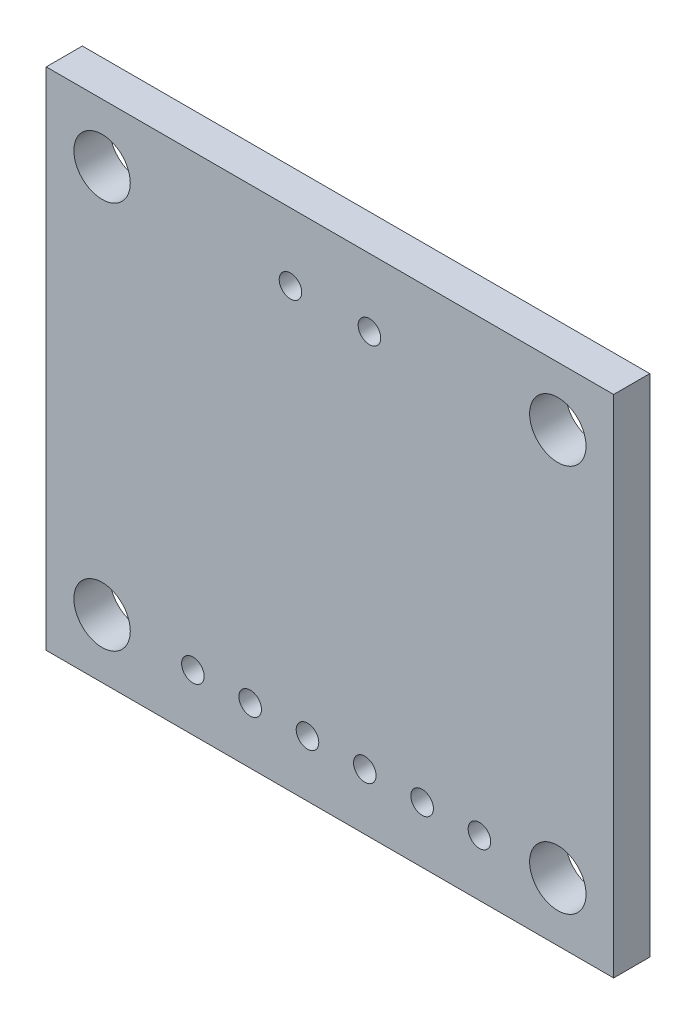
from build123d import *

# Parameters (mm, degrees)
SKETCH1_W           = 25.15
SKETCH1_H           = 22.4
SKETCH1_R           = 1.25
SKETCH1_R_2         = 0.5
BOSS_EXTRUDE1_DEPTH = 1.6


with BuildPart() as part:
    # Sketch1 → Boss-Extrude1 (new body)
    with BuildSketch(Plane.XY):
        Rectangle(SKETCH1_W, SKETCH1_H)
        with Locations((-10.1, 8.6)):
            Circle(SKETCH1_R, mode=Mode.SUBTRACT)
        with Locations((10.1, 8.6)):
            Circle(SKETCH1_R, mode=Mode.SUBTRACT)
        with Locations((-10.1, -8.6)):
            Circle(SKETCH1_R, mode=Mode.SUBTRACT)
        with Locations((10.1, -8.6)):
            Circle(SKETCH1_R, mode=Mode.SUBTRACT)
        with Locations((-1.75, 8.2)):
            Circle(SKETCH1_R_2, mode=Mode.SUBTRACT)
        with Locations((1.75, 8.2)):
            Circle(SKETCH1_R_2, mode=Mode.SUBTRACT)
        with Locations((-6.075, -8.7)):
            Circle(SKETCH1_R_2, mode=Mode.SUBTRACT)
        with Locations((-3.535, -8.7)):
            Circle(SKETCH1_R_2, mode=Mode.SUBTRACT)
        with Locations((-0.995, -8.7)):
            Circle(SKETCH1_R_2, mode=Mode.SUBTRACT)
        with Locations((1.545, -8.7)):
            Circle(SKETCH1_R_2, mode=Mode.SUBTRACT)
        with Locations((4.085, -8.7)):
            Circle(SKETCH1_R_2, mode=Mode.SUBTRACT)
        with Locations((6.625, -8.7)):
            Circle(SKETCH1_R_2, mode=Mode.SUBTRACT)
    extrude(amount=BOSS_EXTRUDE1_DEPTH)


solid = part.part
